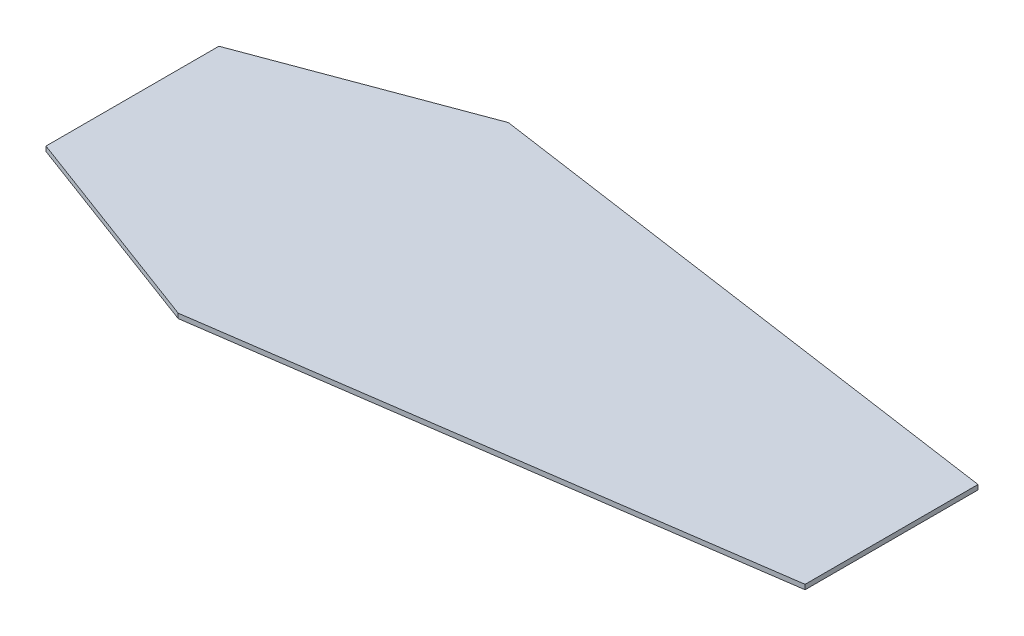
from build123d import *

# Parameters (mm, degrees)
BOSS_EXTRUDE1_DEPTH = 14.2875


with BuildPart() as part:
    # Sketch1 → Boss-Extrude1 (new body)
    with BuildSketch(Plane(origin=(0, 0, 0), x_dir=(1, 0, 0), z_dir=(0, 1, 0))):
        Polygon((-1317.706817207, 355.879097463), (-1317.706817207, -164.820902537), (-682.706817207, -401.564777537), (968.293182793, -164.820902537), (968.293182793, 355.879097463), (-682.706817207, 592.607097463), align=None)
    extrude(amount=BOSS_EXTRUDE1_DEPTH)


solid = part.part
